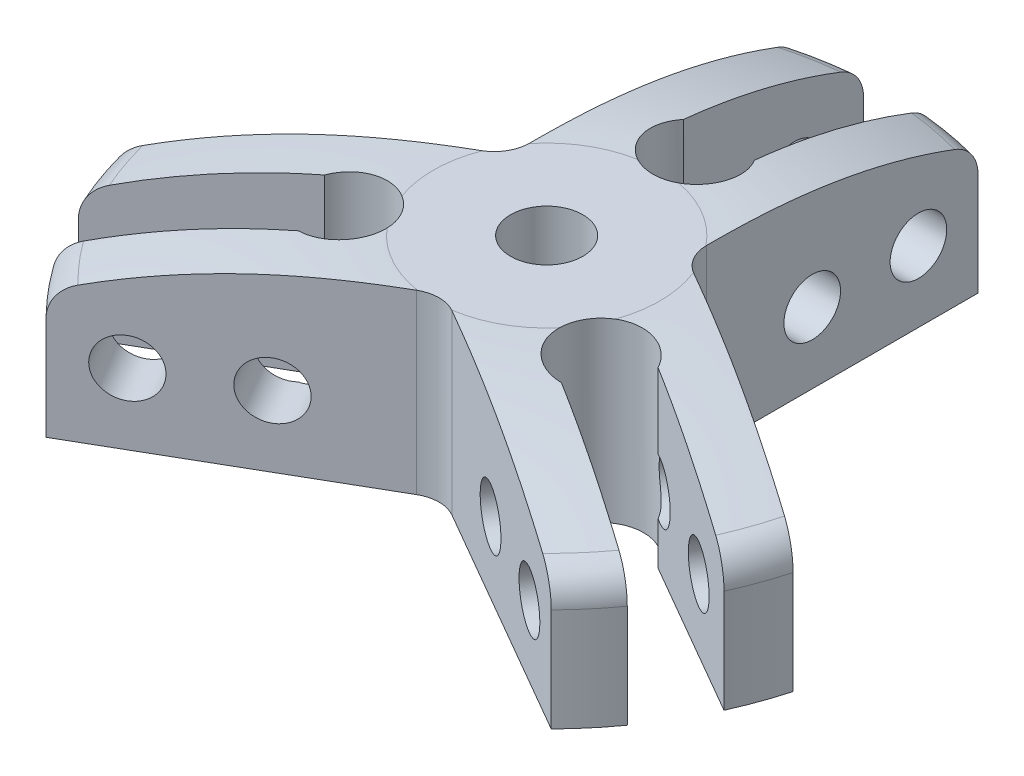
from build123d import *

# Parameters (mm, degrees)
CORTAR_EXTRUIR2_START  = -1
CORTAR_EXTRUIR2_DEPTH  = 27.0000001
MATRIZC1_COUNT         = 3
CORTAR_EXTRUIR4_START  = -26.0000001
CORTAR_EXTRUIR4_DEPTH  = 27.0000002
CROQUIS4_R             = 4
CORTAR_EXTRUIR5_DEPTH  = 61.676274678
MATRIZC2_COUNT         = 3
TALADRO_ROSCADO_M123_D = 10.2


with BuildPart() as part:
    # Croquis1 → Revolución1 (revolve)
    with BuildSketch(Plane.XY):
        with BuildLine():
            Line((0, 0), (0, 25))
            Line((0, 25), (16, 25))
            ThreePointArc((16, 25), (31.675095729, 23.542153275), (46.8125, 19.218620562))
            ThreePointArc((46.8125, 19.218620562), (49.126893505, 17.381599153), (50, 14.558701705))
            Line((50, 14.558701705), (50, 0))
            Line((50, 0), (0, 0))
        make_face()
    revolve(axis=Axis((0, 0, 0), (0, 1, 0)))

    # Croquis2 → Cortar-Extruir2 (cut)
    with BuildSketch(Plane(origin=(0, 0, 0), x_dir=(1, 0, 0), z_dir=(0, 1, 0)).offset(CORTAR_EXTRUIR2_START)):
        with BuildLine():
            Line((12.5, 393.277698575), (12.5, 72.520378778))
            Line((12.5, 72.520378778), (12.5, 10.103629711))
            ThreePointArc((12.5, 10.103629711), (13.169872981, 7.603629711), (15, 5.773502692))
            Line((15, 5.773502692), (81.567409036, -32.659208834))
            Line((81.567409036, -32.659208834), (359.35139643, -193.037868733))
            Line((359.35139643, -193.037868733), (911.48653984, 133.593140553))
            Line((911.48653984, 133.593140553), (564.635143409, 719.908707861))
            Line((564.635143409, 719.908707861), (12.5, 393.277698575))
        make_face()
    cortar_extruir2 = extrude(amount=CORTAR_EXTRUIR2_DEPTH, mode=Mode.SUBTRACT)

    # MatrizC1: Cortar-Extruir2 ×3 about axis
    matrizc1_axis = Axis((0, 0, 0), (0, -1, 0))
    for i in range(1, MATRIZC1_COUNT):
        add(cortar_extruir2.rotate(matrizc1_axis, i * 360 / MATRIZC1_COUNT), mode=Mode.SUBTRACT)

    # Croquis3 → Cortar-Extruir4 (cut)
    with BuildSketch(Plane.XZ.offset(CORTAR_EXTRUIR4_START)):
        with BuildLine():
            Line((5, -283.579531039), (5, -58.462489305))
            Line((5, -58.462489305), (5, -24.31662479))
            ThreePointArc((5, -24.31662479), (0, -15), (-5, -24.31662479))
            Line((-5, -24.31662479), (-5, -58.462489305))
            Line((-5, -58.462489305), (-5, -283.579531039))
            Line((-5, -283.579531039), (-5, -733.813614508))
            Line((-5, -733.813614508), (5, -733.813614508))
            Line((5, -733.813614508), (5, -283.579531039))
        make_face()
    cortar_extruir4 = extrude(amount=CORTAR_EXTRUIR4_DEPTH, mode=Mode.SUBTRACT)

    # Croquis4 → Cortar-Extruir5 (cut, through all)
    with BuildSketch(Plane(origin=(12.5, 0, 0), x_dir=(0, 0, -1), z_dir=(1, 0, 0))):
        with Locations((25, 10)):
            Circle(CROQUIS4_R)
        with Locations((40, 10)):
            Circle(CROQUIS4_R)
    cortar_extruir5 = extrude(amount=-CORTAR_EXTRUIR5_DEPTH, mode=Mode.SUBTRACT)

    # MatrizC2: Cortar-Extruir4, Cortar-Extruir5 ×3 about axis
    matrizc2_axis = Axis((0, 0, 0), (0, -1, 0))
    for i in range(1, MATRIZC2_COUNT):
        add(cortar_extruir4.rotate(matrizc2_axis, i * 360 / MATRIZC2_COUNT), mode=Mode.SUBTRACT)
        add(cortar_extruir5.rotate(matrizc2_axis, i * 360 / MATRIZC2_COUNT), mode=Mode.SUBTRACT)

    # Taladro roscado M123 (through all)
    with Locations(Plane(origin=(0, 25, 0), x_dir=(1, 0, 0), z_dir=(0, 1, 0))):
        with Locations((0, 0)):
            Hole(TALADRO_ROSCADO_M123_D / 2)


solid = part.part
